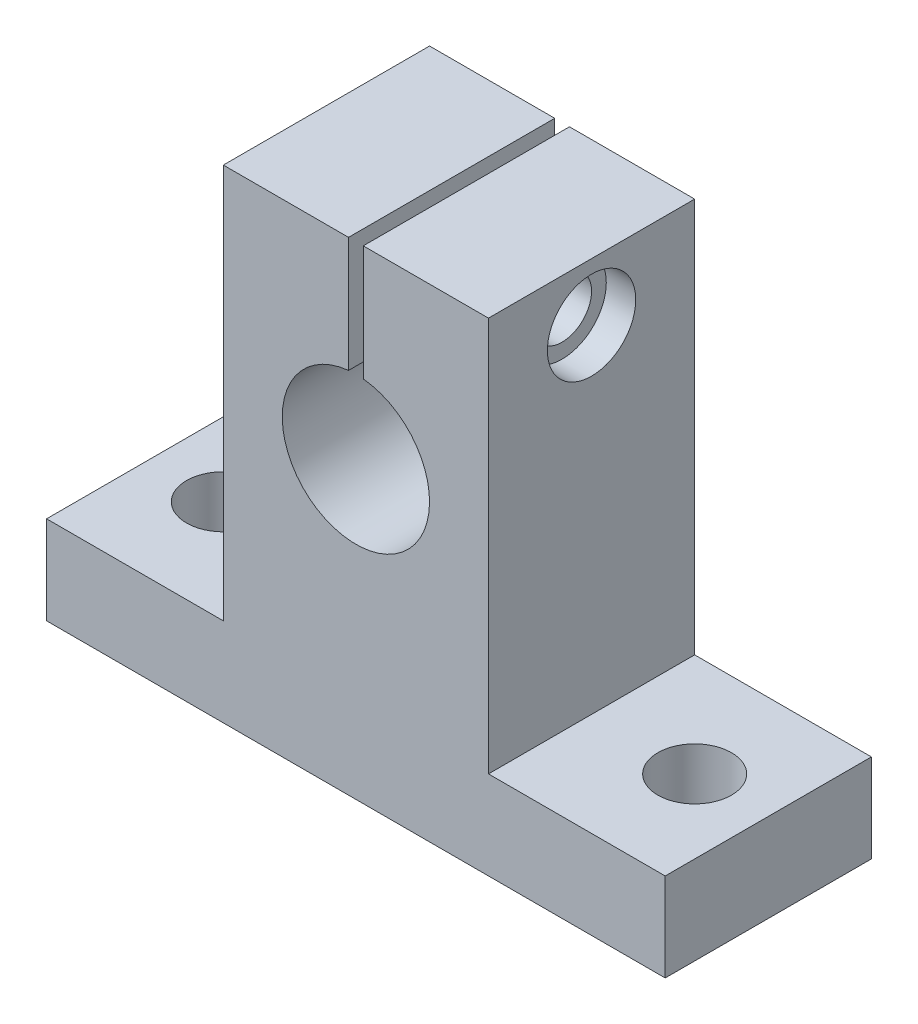
from build123d import *

# Parameters (mm, degrees)
SKETCH_1_R          = 5
EXTRUDE_1_DEPTH     = 14
SKETCH_2_R          = 2.5
CUT_EXTRUDE_1_DEPTH = 7
SKETCH_3_W          = 1
SKETCH_3_H          = 14
CUT_EXTRUDE_2_DEPTH = 14
SKETCH_4_R          = 2
CUT_EXTRUDE_3_DEPTH = 10
SKETCH_5_R          = 3
CUT_EXTRUDE_4_DEPTH = 2


with BuildPart() as part:
    # 草图1 → 凸台-拉伸1 (new body)
    with BuildSketch(Plane.XY):
        Polygon((21, 0), (-21, 0), (-21, 6), (-9, 6), (-9, 32.8), (9, 32.8), (9, 6), (21, 6), align=None)
        with Locations((0, 20)):
            Circle(SKETCH_1_R, mode=Mode.SUBTRACT)
    extrude(amount=EXTRUDE_1_DEPTH)

    # 草图2 → 切除-拉伸1 (cut, through all)
    with BuildSketch(Plane(origin=(0, 6, 0), x_dir=(1, 0, 0), z_dir=(0, 1, 0))):
        with Locations((-16, -7)):
            Circle(SKETCH_2_R)
        with Locations((16, -7)):
            Circle(SKETCH_2_R)
    extrude(amount=-CUT_EXTRUDE_1_DEPTH, mode=Mode.SUBTRACT)

    # 草图3 → 切除-拉伸2 (cut)
    with BuildSketch(Plane(origin=(0, 32.8, 0), x_dir=(1, 0, 0), z_dir=(0, 1, 0))):
        with Locations((0, -7)):
            Rectangle(SKETCH_3_W, SKETCH_3_H)
    extrude(amount=-CUT_EXTRUDE_2_DEPTH, mode=Mode.SUBTRACT)

    # 草图4 → 切除-拉伸3 (cut, symmetric)
    with BuildSketch(Plane(origin=(-0.5, 0, 0), x_dir=(0, 0, -1), z_dir=(1, 0, 0))):
        with Locations((-7, 28.887468593)):
            Circle(SKETCH_4_R)
    extrude(amount=CUT_EXTRUDE_3_DEPTH, both=True, mode=Mode.SUBTRACT)

    # 草图5 → 切除-拉伸4 (cut)
    with BuildSketch(Plane(origin=(9, 0, 0), x_dir=(0, 0, -1), z_dir=(1, 0, 0))):
        with Locations((-7, 28.887468593)):
            Circle(SKETCH_5_R)
    extrude(amount=-CUT_EXTRUDE_4_DEPTH, mode=Mode.SUBTRACT)


solid = part.part
